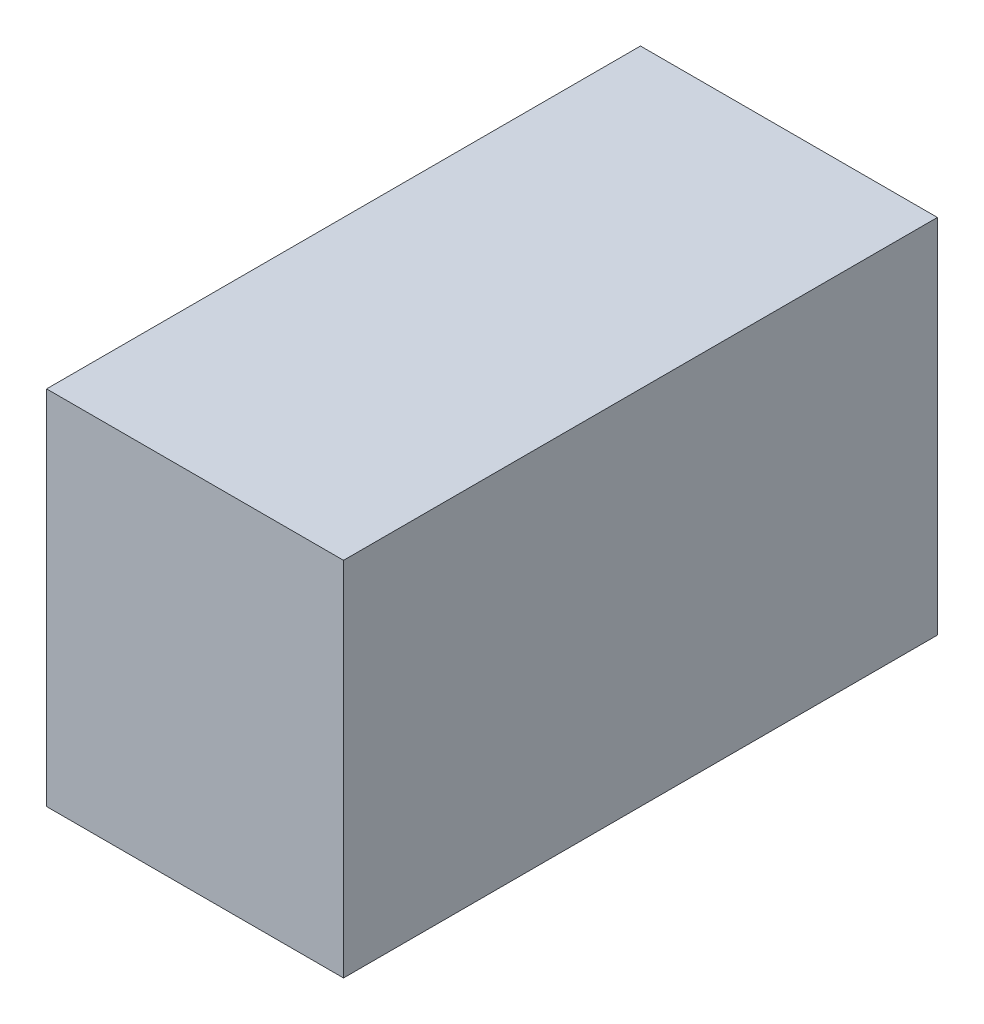
from build123d import *

# Parameters (mm, degrees)
SKETCH_1_W      = 55
SKETCH_1_H      = 67
EXTRUDE_1_DEPTH = 55


with BuildPart() as part:
    # 草图1 → 凸台-拉伸1 (new body, symmetric)
    with BuildSketch(Plane.XY):
        Rectangle(SKETCH_1_W, SKETCH_1_H)
    extrude(amount=EXTRUDE_1_DEPTH, both=True)


solid = part.part
